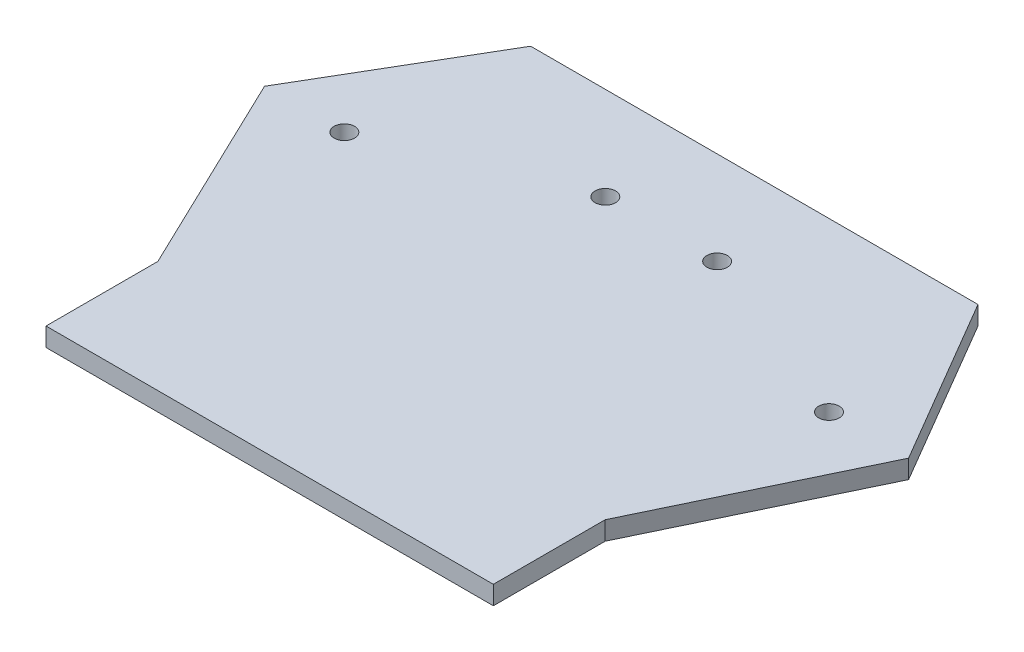
from build123d import *

# Parameters (mm, degrees)
SKETCH2_R           = 2.75
BOSS_EXTRUDE1_DEPTH = 5


with BuildPart() as part:
    # Sketch2 → Boss-Extrude1 (new body)
    with BuildSketch(Plane(origin=(0, 0, 0), x_dir=(1, 0, 0), z_dir=(0, 1, 0))):
        Polygon((-60, 29.972892827), (-60, -0.027107173), (60, -0.027107173), (60, 29.972892827), (86.384328478, 84.972892827), (60, 129.972892827), (-60, 129.972892827), (-86.384328478, 84.972892827), align=None)
        with Locations((-15, 105)):
            Circle(SKETCH2_R, mode=Mode.SUBTRACT)
        with Locations((-65, 85)):
            Circle(SKETCH2_R, mode=Mode.SUBTRACT)
        with Locations((65, 85)):
            Circle(SKETCH2_R, mode=Mode.SUBTRACT)
        with Locations((15, 105)):
            Circle(SKETCH2_R, mode=Mode.SUBTRACT)
    extrude(amount=BOSS_EXTRUDE1_DEPTH)


solid = part.part
